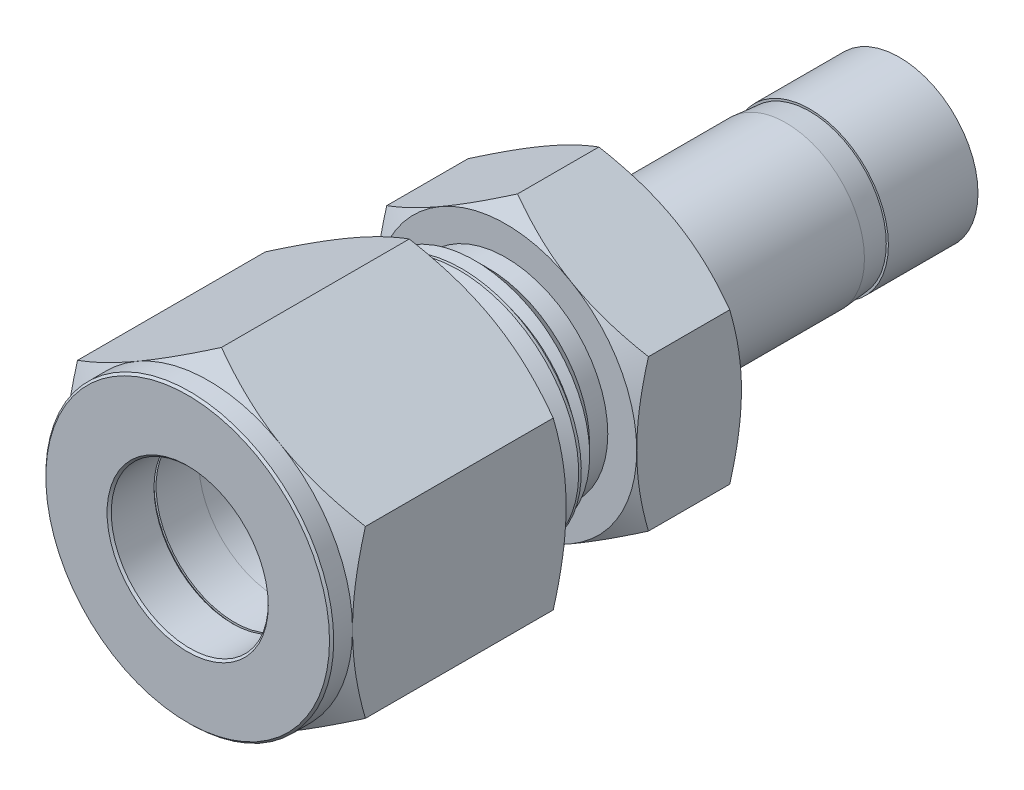
from build123d import *

# Parameters (mm, degrees)
BOSS_EXTRUDE1_DEPTH    = 14.224
CHAMFER1_SIZE          = 0.127
SKETCH4_W              = 11.938
SKETCH4_H              = 7.14375
CUT_SWEEP1_PITCH       = 1.27
CUT_SWEEP1_HEIGHT      = 13.208
CUT_SWEEP1_RADIUS      = 7.14375
CUT_SWEEP1_START_ANGLE = 90
BOSS_EXTRUDE2_DEPTH    = 6.35


with BuildPart() as part:
    # Sketch2 → Boss-Extrude1 (new body)
    with BuildSketch(Plane.XY):
        Polygon((0, 10.081979076), (-8.73125, 5.040989538), (-8.73125, -5.040989538), (0, -10.081979076), (8.73125, -5.040989538), (8.73125, 5.040989538), align=None)
    extrude(amount=-BOSS_EXTRUDE1_DEPTH)

    # Sketch3 → Cut-Revolve1 (revolve, cut)
    with BuildSketch(Plane(origin=(0, 0, 0), x_dir=(0, 0, -1), z_dir=(1, 0, 0)), mode=Mode.PRIVATE) as cut_revolve1_sk:
        Polygon((0, 10.081979076), (0, 8.73125), (1.27, 8.73125), (2.049843795, 10.081979076), (13.444156205, 10.081979076), (14.224, 8.73125), (14.224, 10.081979076), (14.224, 11.432708151), (0, 11.432708151), align=None)
        Polygon((0, 4.7625), (0, 0), (14.224, 0), (14.224, 7.14375), (5.6896, 7.14375), (5.6896, 6.50875), (2.8448, 6.50875), (2.8448, 5.87375), (2.8448, 4.7625), align=None)
    revolve(cut_revolve1_sk.sketch.rotate(Axis((0, 0, 0), (0, 0, -1)), 90), axis=Axis((0, 0, 0), (0, 0, -1)), mode=Mode.SUBTRACT)

    # Chamfer1
    chamfer1_edges = [part.edges().sort_by_distance(p)[0] for p in [
        (-8.73125, 0, 0),
        (-4.7625, 0, -2.8448),
        (-4.7625, 0, 0),
    ]]
    chamfer(chamfer1_edges, length=CHAMFER1_SIZE)


with BuildPart() as body_2:
    # Sketch4 → Revolve1 (revolve)
    with BuildSketch(Plane(origin=(0, 0, 0), x_dir=(0, 0, -1), z_dir=(1, 0, 0)), mode=Mode.PRIVATE) as revolve1_sk:
        with Locations((13.335, 3.571875)):
            Rectangle(SKETCH4_W, SKETCH4_H)
    revolve(revolve1_sk.sketch.rotate(Axis((0, 0, -19.304), (0, 0, 1)), 90), axis=Axis((0, 0, -19.304), (0, 0, 1)))

    # Cut-Sweep1: sweep along a helix
    with BuildLine() as cut_sweep1_path:
        add(Helix(CUT_SWEEP1_PITCH, CUT_SWEEP1_HEIGHT, CUT_SWEEP1_RADIUS, center=(0, 0, -7.366), direction=(0, 0, -1), mode=Mode.PRIVATE).rotate(Axis((0, 0, -7.366), (0, 0, -1)), CUT_SWEEP1_START_ANGLE))
    # Sketch6 → Cut-Sweep1 (sweep, cut)
    with BuildSketch(Plane(origin=(0, 0, 0), x_dir=(0, 0, -1), z_dir=(1, 0, 0))):
        Polygon((6.731, 6.318860803), (6.2150625, 7.212490766), (7.4056875, 7.212490766), (6.88975, 6.318860803), align=None)
    sweep(path=cut_sweep1_path.line, is_frenet=True, mode=Mode.SUBTRACT)

    # Sketch7 → Boss-Extrude2 (add)
    with BuildSketch(Plane(origin=(0, 0, -19.304), x_dir=(-1, 0, 0), z_dir=(0, 0, -1))):
        Polygon((0, 9.165435523), (-7.9375, 4.582717762), (-7.9375, -4.582717762), (0, -9.165435523), (7.9375, -4.582717762), (7.9375, 4.582717762), align=None)
    extrude(amount=BOSS_EXTRUDE2_DEPTH)

    # Sketch8 → Cut-Revolve2 (revolve, cut)
    with BuildSketch(Plane(origin=(0, 0, 0), x_dir=(0, 0, -1), z_dir=(1, 0, 0)), mode=Mode.PRIVATE) as cut_revolve2_sk:
        Polygon((7.366, 7.281231533), (7.366, 6.18137927), (8.465852263, 7.281231533), align=None)
        Polygon((19.304, 7.281231533), (17.104295474, 7.281231533), (18.204147737, 6.18137927), (19.304, 6.18137927), align=None)
        Polygon((19.304, 7.9375), (20.012948905, 9.165435523), (24.945051095, 9.165435523), (25.654, 7.9375), (25.654, 9.165435523), (25.654, 10.393371047), (19.304, 10.393371047), (19.304, 9.165435523), align=None)
        Polygon((17.018, 3.556), (25.654, 3.556), (25.654, 0), (7.366, 0), (7.366, 5.642404948), (10.922668421, 4.7625), (17.018, 4.7625), align=None)
    revolve(cut_revolve2_sk.sketch.rotate(Axis((0, 0, 0), (0, 0, -1)), 90), axis=Axis((0, 0, 0), (0, 0, -1)), mode=Mode.SUBTRACT)

    # Sketch11 → Revolve4 (revolve)
    with BuildSketch(Plane(origin=(0, 0, 0), x_dir=(0, 0, -1), z_dir=(1, 0, 0)), mode=Mode.PRIVATE) as revolve4_sk:
        Polygon((25.654, 3.556), (43.18, 3.556), (43.18, 4.7625), (37.7444, 4.7625), (37.7444, 4.6355), (36.292783358, 4.7625), (25.654, 4.7625), align=None)
    revolve(revolve4_sk.sketch.rotate(Axis((0, 0, 0), (0, 0, -1)), 90), axis=Axis((0, 0, 0), (0, 0, -1)))


with BuildPart() as body_3:
    # Sketch9 → Revolve2 (revolve)
    with BuildSketch(Plane(origin=(0, 0, 0), x_dir=(0, 0, -1), z_dir=(1, 0, 0)), mode=Mode.PRIVATE) as revolve2_sk:
        Polygon((4.7625, 6.2865), (4.7625, 5.4356), (5.4356, 4.7625), (9.6393, 4.7625), (9.6393, 5.08), align=None)
    revolve(revolve2_sk.sketch.rotate(Axis((0, 0, 0), (0, 0, -1)), 90), axis=Axis((0, 0, 0), (0, 0, -1)))


with BuildPart() as body_4:
    # Sketch10 → Revolve3 (revolve)
    with BuildSketch(Plane(origin=(0, 0, 0), x_dir=(0, 0, -1), z_dir=(1, 0, 0)), mode=Mode.PRIVATE) as revolve3_sk:
        Polygon((2.8448, 6.223), (3.9878, 6.223), (3.9878, 5.4356), (4.7625, 5.4356), (5.4356, 4.7625), (2.8448, 4.7625), align=None)
    revolve(revolve3_sk.sketch.rotate(Axis((0, 0, 0), (0, 0, -1)), 90), axis=Axis((0, 0, 0), (0, 0, -1)))


solid = Compound([part.part, body_2.part, body_3.part, body_4.part])
